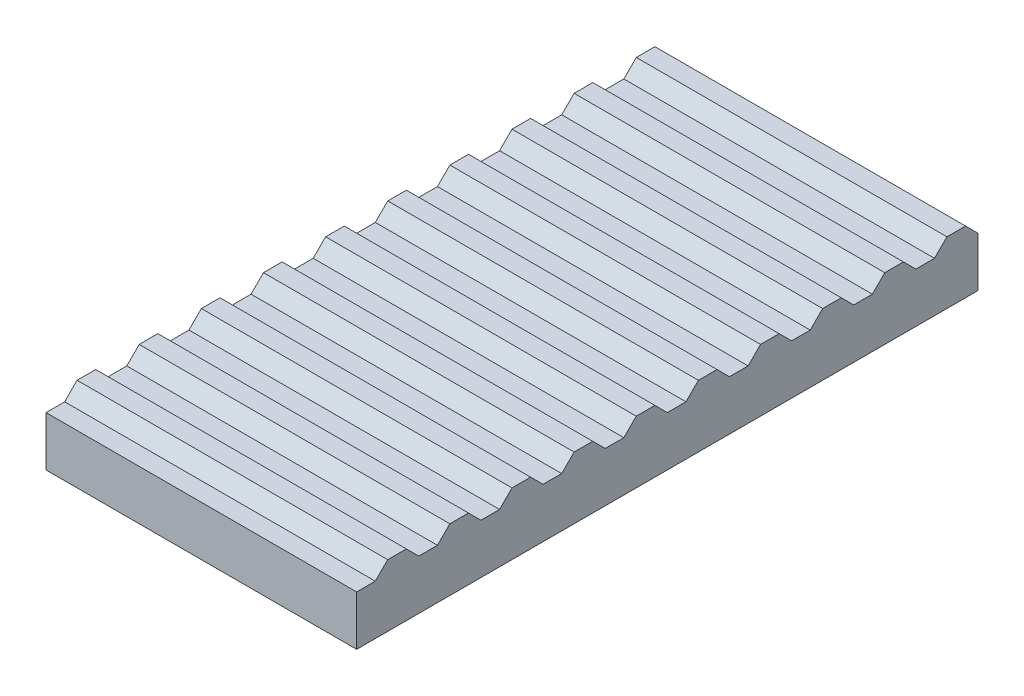
from build123d import *

# Parameters (mm, degrees)
EXTRUDE_1_DEPTH = 10


with BuildPart() as part:
    # 草图2 → 凸台-拉伸1 (new body)
    with BuildSketch(Plane(origin=(0, 0, 0), x_dir=(0, 0, -1), z_dir=(1, 0, 0))):
        Polygon((-10, 0), (10, 0), (10, 1.6), (9.6, 2), (9, 2), (8.6, 1.6), (8, 1.6), (7.6, 2), (7, 2), (6.6, 1.6), (6, 1.6), (5.6, 2), (5, 2), (4.6, 1.6), (4, 1.6), (3.6, 2), (3, 2), (2.6, 1.6), (2, 1.6), (1.6, 2), (1, 2), (0.6, 1.6), (0, 1.6), (-0.4, 2), (-1, 2), (-1.4, 1.6), (-2, 1.6), (-2.4, 2), (-3, 2), (-3.4, 1.6), (-4, 1.6), (-4.4, 2), (-5, 2), (-5.4, 1.6), (-6, 1.6), (-6.4, 2), (-7, 2), (-7.4, 1.6), (-8, 1.6), (-8.4, 2), (-9, 2), (-9.4, 1.6), (-10, 1.6), align=None)
    extrude(amount=EXTRUDE_1_DEPTH)


solid = part.part
